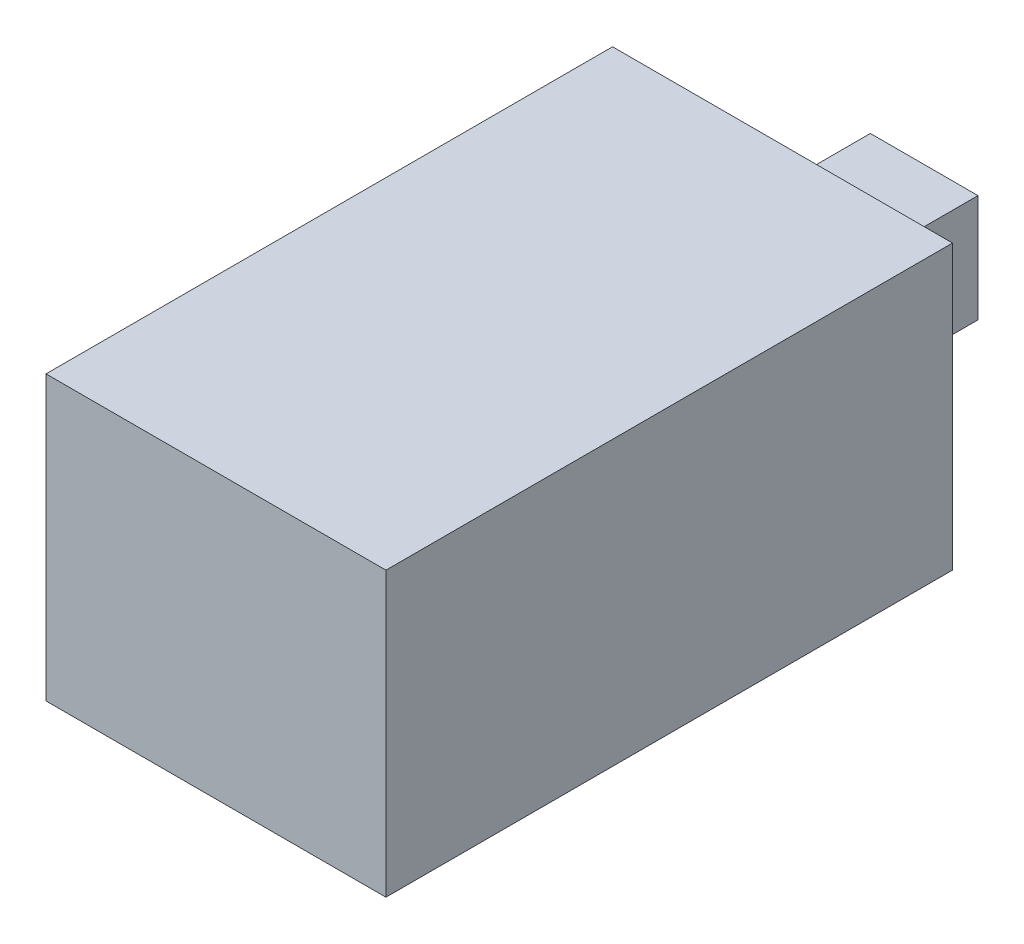
from build123d import *

# Parameters (mm, degrees)
SKETCH1_W           = 12
SKETCH1_H           = 10
BOSS_EXTRUDE1_DEPTH = 20
SKETCH2_W           = 3.8
SKETCH2_H           = 3.8
BOSS_EXTRUDE2_DEPTH = 5


with BuildPart() as part:
    # Sketch1 → Boss-Extrude1 (new body)
    with BuildSketch(Plane.XY):
        Rectangle(SKETCH1_W, SKETCH1_H)
    extrude(amount=BOSS_EXTRUDE1_DEPTH)

    # Sketch2 → Boss-Extrude2 (add)
    with BuildSketch(Plane(origin=(0, 0, 0), x_dir=(-1, 0, 0), z_dir=(0, 0, -1))):
        Rectangle(SKETCH2_W, SKETCH2_H)
    extrude(amount=BOSS_EXTRUDE2_DEPTH)


solid = part.part
